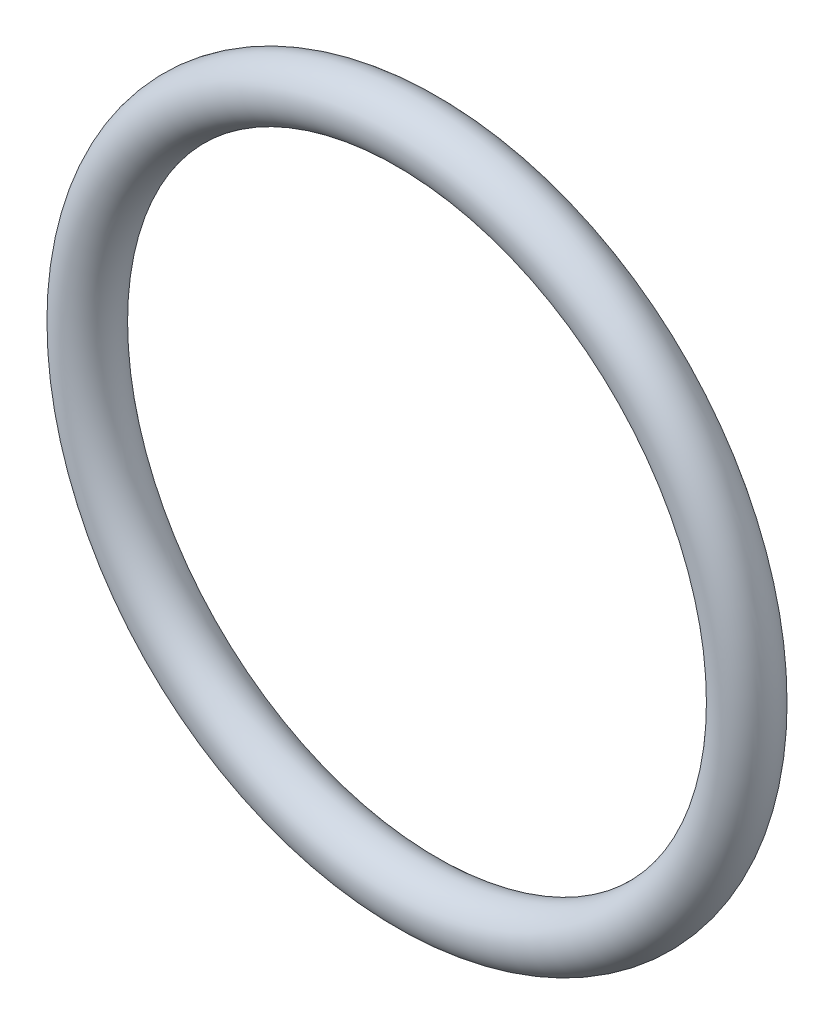
from build123d import *

# Parameters (mm, degrees)
SKETCH1_R = 0.889


with BuildPart() as part:
    # Sketch1 → Revolve1 (revolve)
    with BuildSketch(Plane(origin=(0, 0, 0), x_dir=(1, 0, 0), z_dir=(0, 1, 0))):
        with Locations((10.2743, 0)):
            Circle(SKETCH1_R)
    revolve(axis=Axis((0, 0, -0.889), (0, 0, 1)))


solid = part.part
